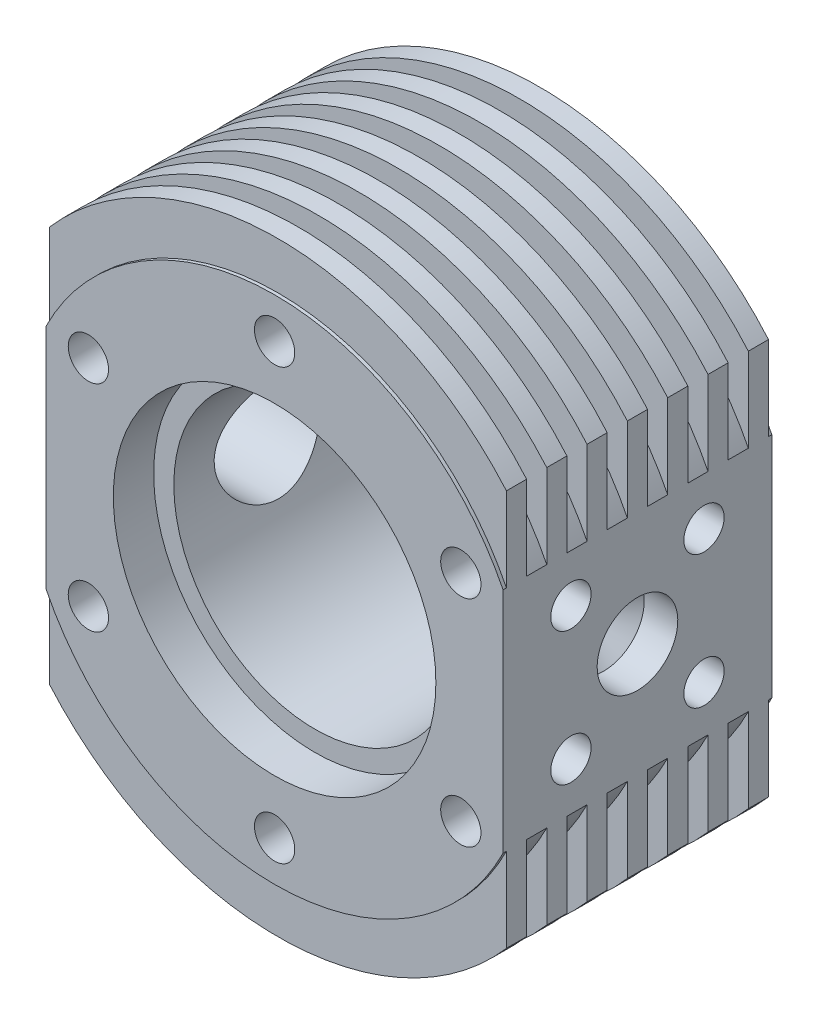
from build123d import *

# Parameters (mm, degrees)
SKETCH1_R            = 10.5
BOSS_EXTRUDE1_DEPTH  = 20
SKETCH2_R            = 12
CUT_EXTRUDE1_DEPTH   = 3
SKETCH3_OUTSIDE_W    = 47.968
SKETCH3_OUTSIDE_H    = 58.968
SKETCH3_OUTSIDE_R    = 19
CUT_EXTRUDE2_DEPTH   = 0.25
SKETCH4_OUTSIDE_W    = 47.968
SKETCH4_OUTSIDE_H    = 58.968
SKETCH4_OUTSIDE_R    = 19
CUT_EXTRUDE3_DEPTH   = 0.25
CUT_EXTRUDE4_DEPTH   = 1.5
LPATTERN1_COUNT      = 6
LPATTERN1_PITCH      = 3
MIRROR1_COPY_1_DEPTH = 1.5
MIRROR1_COPY_2_DEPTH = 1.5
MIRROR1_COPY_3_DEPTH = 1.5
MIRROR1_COPY_4_DEPTH = 1.5
MIRROR1_COPY_5_DEPTH = 1.5
CUT_EXTRUDE5_REACH   = 36
SKETCH6_R            = 4
SKETCH7_R            = 1.5
CUT_EXTRUDE6_DEPTH   = 4
SKETCH9_R            = 1.5
CUT_EXTRUDE7_DEPTH   = 6


with BuildPart() as part:
    # Sketch1 → Boss-Extrude1 (new body)
    with BuildSketch(Plane.XY):
        with BuildLine():
            Line((-17, 14.739402973), (-17, -14.739402973))
            ThreePointArc((-17, -14.739402973), (0, -22.5), (17, -14.739402973))
            Line((17, -14.739402973), (17, 14.739402973))
            ThreePointArc((17, 14.739402973), (0, 22.5), (-17, 14.739402973))
        make_face()
        Circle(SKETCH1_R, mode=Mode.SUBTRACT)
    extrude(amount=BOSS_EXTRUDE1_DEPTH)

    # Sketch2 → Cut-Extrude1 (cut)
    with BuildSketch(Plane.XY.offset(20)):
        Circle(SKETCH2_R)
    extrude(amount=-CUT_EXTRUDE1_DEPTH, mode=Mode.SUBTRACT)

    # Sketch3 outside → Cut-Extrude2 (cut)
    with BuildSketch(Plane(origin=(0, 0, 0), x_dir=(-1, 0, 0), z_dir=(0, 0, -1))):
        Rectangle(SKETCH3_OUTSIDE_W, SKETCH3_OUTSIDE_H)
        Circle(SKETCH3_OUTSIDE_R, mode=Mode.SUBTRACT)
    extrude(amount=-CUT_EXTRUDE2_DEPTH, mode=Mode.SUBTRACT)

    # Sketch4 outside → Cut-Extrude3 (cut)
    with BuildSketch(Plane.XY.offset(20)):
        Rectangle(SKETCH4_OUTSIDE_W, SKETCH4_OUTSIDE_H)
        Circle(SKETCH4_OUTSIDE_R, mode=Mode.SUBTRACT)
    extrude(amount=-CUT_EXTRUDE3_DEPTH, mode=Mode.SUBTRACT)

    # Sketch5 → Cut-Extrude4 (cut)
    with BuildSketch(Plane(origin=(0, 0, 1.75), x_dir=(-1, 0, 0), z_dir=(0, 0, -1))):
        with BuildLine():
            Line((17, 8.485281374), (17, 14.739402973))
            ThreePointArc((17, 14.739402973), (0, 22.5), (-17, 14.739402973))
            Line((-17, 14.739402973), (-17, 8.485281374))
            ThreePointArc((-17, 8.485281374), (0, 19), (17, 8.485281374))
        make_face()
    cut_extrude4 = extrude(amount=-CUT_EXTRUDE4_DEPTH, mode=Mode.SUBTRACT)

    # LPattern1: Cut-Extrude4 ×6
    with Locations(*[(0, 0, i * LPATTERN1_PITCH) for i in range(1, LPATTERN1_COUNT)]):
        add(cut_extrude4, mode=Mode.SUBTRACT)

    # Mirror1: Cut-Extrude4 across plane
    add(cut_extrude4.mirror(Plane.ZX), mode=Mode.SUBTRACT)

    # Mirror1 copy 1 sketch → Mirror1 copy 1 (cut)
    with BuildSketch(Plane(origin=(0, 0, 4.75), x_dir=(-1, 0, 0), z_dir=(0, 0, -1))):
        with BuildLine():
            Line((17, -8.485281374), (17, -14.739402973))
            ThreePointArc((17, -14.739402973), (0, -22.5), (-17, -14.739402973))
            Line((-17, -14.739402973), (-17, -8.485281374))
            ThreePointArc((-17, -8.485281374), (0, -19), (17, -8.485281374))
        make_face()
    extrude(amount=-MIRROR1_COPY_1_DEPTH, mode=Mode.SUBTRACT)

    # Mirror1 copy 2 sketch → Mirror1 copy 2 (cut)
    with BuildSketch(Plane(origin=(0, 0, 7.75), x_dir=(-1, 0, 0), z_dir=(0, 0, -1))):
        with BuildLine():
            Line((17, -8.485281374), (17, -14.739402973))
            ThreePointArc((17, -14.739402973), (0, -22.5), (-17, -14.739402973))
            Line((-17, -14.739402973), (-17, -8.485281374))
            ThreePointArc((-17, -8.485281374), (0, -19), (17, -8.485281374))
        make_face()
    extrude(amount=-MIRROR1_COPY_2_DEPTH, mode=Mode.SUBTRACT)

    # Mirror1 copy 3 sketch → Mirror1 copy 3 (cut)
    with BuildSketch(Plane(origin=(0, 0, 10.75), x_dir=(-1, 0, 0), z_dir=(0, 0, -1))):
        with BuildLine():
            Line((17, -8.485281374), (17, -14.739402973))
            ThreePointArc((17, -14.739402973), (0, -22.5), (-17, -14.739402973))
            Line((-17, -14.739402973), (-17, -8.485281374))
            ThreePointArc((-17, -8.485281374), (0, -19), (17, -8.485281374))
        make_face()
    extrude(amount=-MIRROR1_COPY_3_DEPTH, mode=Mode.SUBTRACT)

    # Mirror1 copy 4 sketch → Mirror1 copy 4 (cut)
    with BuildSketch(Plane(origin=(0, 0, 13.75), x_dir=(-1, 0, 0), z_dir=(0, 0, -1))):
        with BuildLine():
            Line((17, -8.485281374), (17, -14.739402973))
            ThreePointArc((17, -14.739402973), (0, -22.5), (-17, -14.739402973))
            Line((-17, -14.739402973), (-17, -8.485281374))
            ThreePointArc((-17, -8.485281374), (0, -19), (17, -8.485281374))
        make_face()
    extrude(amount=-MIRROR1_COPY_4_DEPTH, mode=Mode.SUBTRACT)

    # Mirror1 copy 5 sketch → Mirror1 copy 5 (cut)
    with BuildSketch(Plane(origin=(0, 0, 16.75), x_dir=(-1, 0, 0), z_dir=(0, 0, -1))):
        with BuildLine():
            Line((17, -8.485281374), (17, -14.739402973))
            ThreePointArc((17, -14.739402973), (0, -22.5), (-17, -14.739402973))
            Line((-17, -14.739402973), (-17, -8.485281374))
            ThreePointArc((-17, -8.485281374), (0, -19), (17, -8.485281374))
        make_face()
    extrude(amount=-MIRROR1_COPY_5_DEPTH, mode=Mode.SUBTRACT)

    # Sketch6 → Cut-Extrude5 (cut, up to next)
    with BuildSketch(Plane.ZY.offset(17), mode=Mode.PRIVATE) as cut_extrude5_sk1:
        with Locations((10, 0)):
            Circle(SKETCH6_R)
    cut_extrude5_tool1 = extrude(cut_extrude5_sk1.sketch, amount=-CUT_EXTRUDE5_REACH, mode=Mode.PRIVATE) & part.part
    add(cut_extrude5_tool1.solids().sort_by_distance((-17, 0, 10))[0], mode=Mode.SUBTRACT)

    # Sketch7 → Cut-Extrude6 (cut)
    with BuildSketch(Plane.ZY.offset(17)):
        with Locations((5.050252532, 4.949747468)):
            Circle(SKETCH7_R)
        with Locations((14.949747468, 4.949747468)):
            Circle(SKETCH7_R)
        with Locations((14.949747468, -4.949747468)):
            Circle(SKETCH7_R)
        with Locations((5.050252532, -4.949747468)):
            Circle(SKETCH7_R)
    cut_extrude6 = extrude(amount=-CUT_EXTRUDE6_DEPTH, mode=Mode.SUBTRACT)

    # Sketch8 → Cut-Revolve1 (revolve, cut)
    with BuildSketch(Plane(origin=(0, 0, 10), x_dir=(-1, 0, 0), z_dir=(0, 0, -1))):
        Polygon((-17, 0), (-17, -3), (-14.5, -3), (-11.5, 0), align=None)
    revolve(axis=Axis((11.5, 0, 10), (1, 0, 0)), mode=Mode.SUBTRACT)

    # Mirror2: Cut-Extrude6 across plane
    add(cut_extrude6.mirror(Plane(origin=(0, 0, 0), x_dir=(0, 0, 1), z_dir=(1, 0, 0))), mode=Mode.SUBTRACT)

    # Sketch9 → Cut-Extrude7 (cut)
    with BuildSketch(Plane(origin=(0, 0, 0), x_dir=(-1, 0, 0), z_dir=(0, 0, -1))):
        with Locations((0, 16)):
            Circle(SKETCH9_R)
        with Locations((13.856406461, 8)):
            Circle(SKETCH9_R)
        with Locations((13.856406461, -8)):
            Circle(SKETCH9_R)
        with Locations((0, -16)):
            Circle(SKETCH9_R)
        with Locations((-13.856406461, -8)):
            Circle(SKETCH9_R)
        with Locations((-13.856406461, 8)):
            Circle(SKETCH9_R)
    cut_extrude7 = extrude(amount=-CUT_EXTRUDE7_DEPTH, mode=Mode.SUBTRACT)

    # Mirror3: Cut-Extrude7 across plane
    add(cut_extrude7.mirror(Plane(origin=(0, 0, 10), x_dir=(1, 0, 0), z_dir=(0, 0, -1))), mode=Mode.SUBTRACT)


solid = part.part
